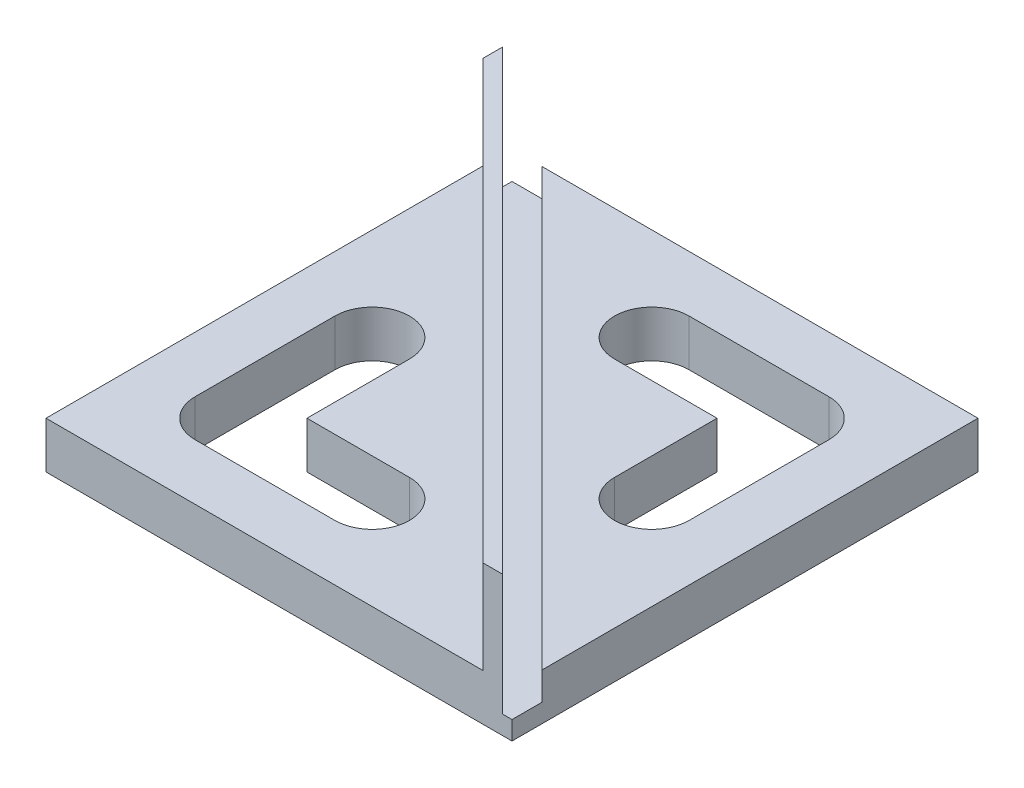
from build123d import *

# Parameters (mm, degrees)
SKETCH1_W           = 50
SKETCH1_H           = 50
BOSS_EXTRUDE1_DEPTH = 5
BOSS_EXTRUDE2_DEPTH = 10
CUT_EXTRUDE1_DEPTH  = 3
SKETCH4_R           = 1.65
CUT_EXTRUDE2_DEPTH  = 38.562445841


with BuildPart() as part:
    # Sketch1 → Boss-Extrude1 (new body)
    with BuildSketch(Plane(origin=(0, 0, 0), x_dir=(1, 0, 0), z_dir=(0, 1, 0))):
        Rectangle(SKETCH1_W, SKETCH1_H)
        with BuildLine():
            Line((15, 19), (0, 19))
            ThreePointArc((0, 19), (-4, 15), (0, 11))
            Line((0, 11), (11, 11))
            Line((11, 11), (11, 0))
            ThreePointArc((11, 0), (15, -4), (19, 0))
            Line((19, 0), (19, 15))
            ThreePointArc((19, 15), (17.828427125, 17.828427125), (15, 19))
        make_face(mode=Mode.SUBTRACT)
        with BuildLine():
            Line((-15, -19), (0, -19))
            ThreePointArc((0, -19), (4, -15), (0, -11))
            Line((0, -11), (-11, -11))
            Line((-11, -11), (-11, 0))
            ThreePointArc((-11, 0), (-15, 4), (-19, 0))
            Line((-19, 0), (-19, -15))
            ThreePointArc((-19, -15), (-17.828427125, -17.828427125), (-15, -19))
        make_face(mode=Mode.SUBTRACT)
    extrude(amount=BOSS_EXTRUDE1_DEPTH)

    # Sketch2 → Boss-Extrude2 (add)
    with BuildSketch(Plane(origin=(0, 5, 0), x_dir=(1, 0, 0), z_dir=(0, 1, 0))):
        Polygon((-25, 21.878679656), (21.878679656, -25), (24, -25), (-25, 24), align=None)
    extrude(amount=BOSS_EXTRUDE2_DEPTH)

    # Sketch3 → Cut-Extrude1 (cut)
    with BuildSketch(Plane(origin=(0, 5, 0), x_dir=(1, 0, 0), z_dir=(0, 1, 0))):
        Polygon((-21.757359313, 25), (25, -21.757359313), (25, -25), (24, -25), (-25, 24), (-25, 25), align=None)
    extrude(amount=-CUT_EXTRUDE1_DEPTH, mode=Mode.SUBTRACT)

    # Sketch4 → Cut-Extrude2 (cut, through all)
    with BuildSketch(Plane(origin=(-1.560660172, 0, 1.560660172), x_dir=(0.707106781, 0, 0.707106781), z_dir=(-0.707106781, 0, 0.707106781))):
        with Locations((-31.148232278, 10)):
            Circle(SKETCH4_R)
        with Locations((23.851767722, 10)):
            Circle(SKETCH4_R)
        with Locations((29.351767722, 10)):
            Circle(SKETCH4_R)
        with Locations((-25.648232278, 10)):
            Circle(SKETCH4_R)
    extrude(amount=-CUT_EXTRUDE2_DEPTH, mode=Mode.SUBTRACT)


solid = part.part
